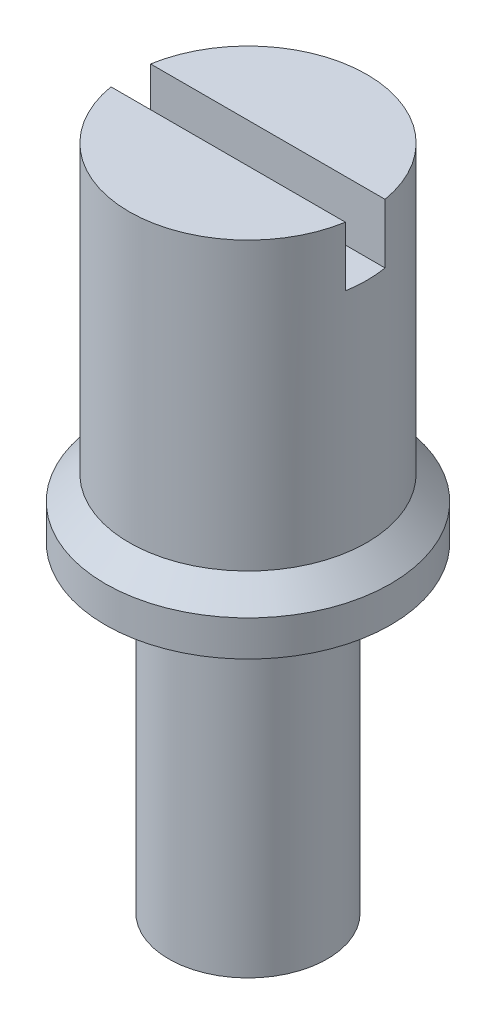
from build123d import *

# Parameters (mm, degrees)
SKETCH3_W          = 6
SKETCH3_H          = 1
CUT_EXTRUDE1_DEPTH = 1.5


with BuildPart() as part:
    # Sketch2 → Revolve1 (revolve)
    with BuildSketch(Plane.XY):
        Polygon((0, -8.1), (2, -8.1), (2, 0), (3.6, 0), (3.6, 0.9), (3, 1.5), (3, 8.73125), (0, 8.73125), align=None)
    revolve(axis=Axis((0, 43.323370715, 0), (0, -1, 0)))

    # Sketch3 → Cut-Extrude1 (cut)
    with BuildSketch(Plane(origin=(0, 8.73125, 0), x_dir=(1, 0, 0), z_dir=(0, 1, 0))):
        Rectangle(SKETCH3_W, SKETCH3_H)
    extrude(amount=-CUT_EXTRUDE1_DEPTH, mode=Mode.SUBTRACT)


solid = part.part
